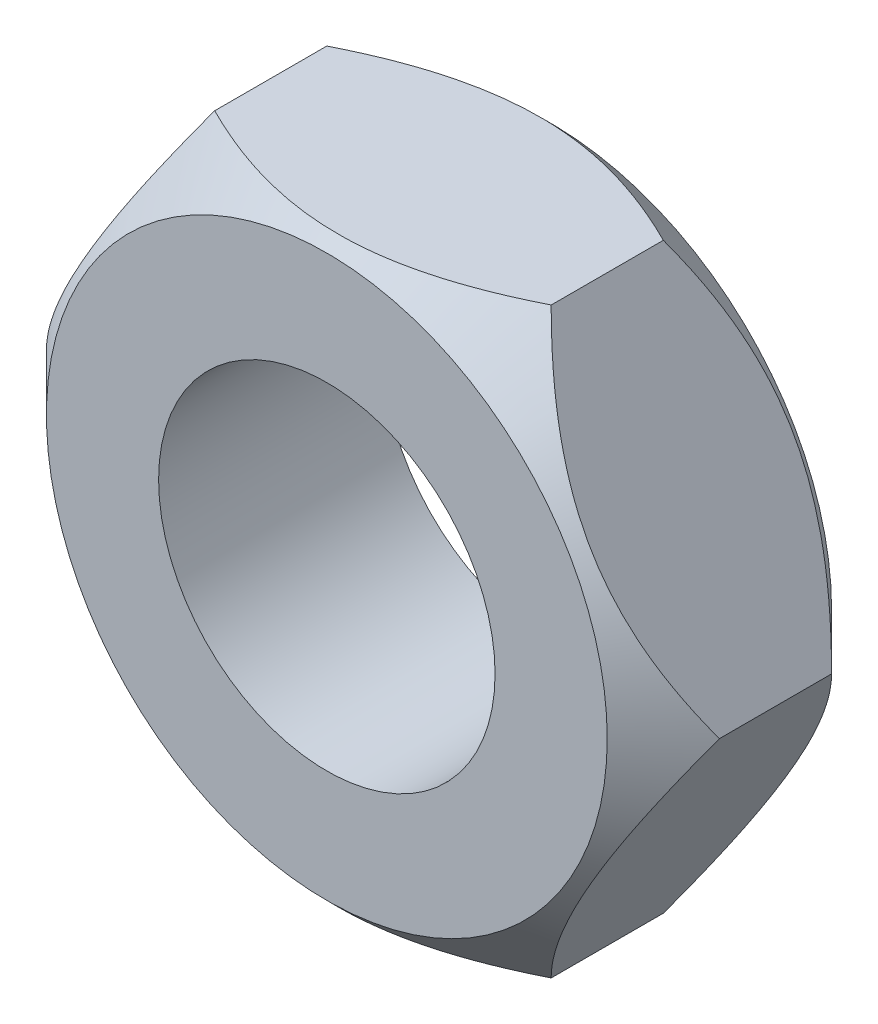
from build123d import *

# Parameters (mm, degrees)
SKETCH1_R           = 4.5
BOSS_EXTRUDE1_DEPTH = 3
SKETCH4_OUTSIDE_W   = 36.912
SKETCH4_OUTSIDE_H   = 34.5
SKETCH4_OUTSIDE_R   = 7.5
CUT_EXTRUDE1_DEPTH  = 6
CUT_EXTRUDE1_TAPER  = 45


with BuildPart() as part:
    # Sketch1 → Boss-Extrude1 (new body, symmetric)
    with BuildSketch(Plane.XY):
        Polygon((4.5, 7.794228634), (-4.5, 7.794228634), (-9, 0), (-4.5, -7.794228634), (4.5, -7.794228634), (9, 0), align=None)
        Circle(SKETCH1_R, mode=Mode.SUBTRACT)
    extrude(amount=BOSS_EXTRUDE1_DEPTH, both=True)

    # Sketch4 outside → Cut-Extrude1 (cut)
    with BuildSketch(Plane.XY.offset(3)):
        Rectangle(SKETCH4_OUTSIDE_W, SKETCH4_OUTSIDE_H)
        Circle(SKETCH4_OUTSIDE_R, mode=Mode.SUBTRACT)
    cut_extrude1 = extrude(amount=-CUT_EXTRUDE1_DEPTH, taper=CUT_EXTRUDE1_TAPER, mode=Mode.SUBTRACT)

    # Mirror1: Cut-Extrude1 across plane
    add(cut_extrude1.mirror(Plane.XY), mode=Mode.SUBTRACT)


solid = part.part
